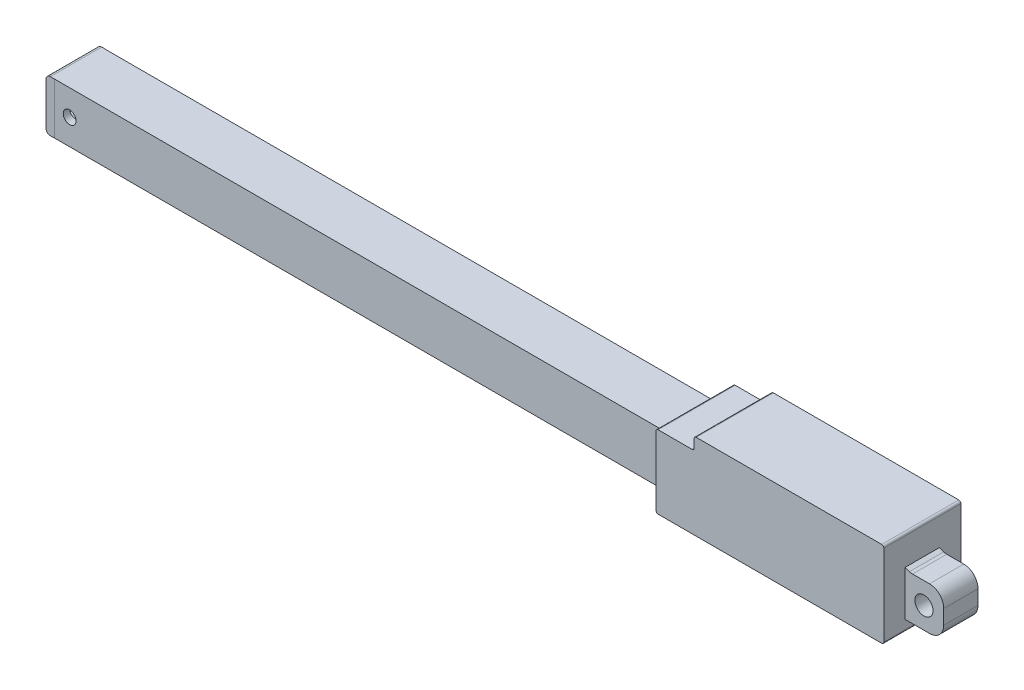
from build123d import *

# Parameters (mm, degrees)
SKETCH2_R           = 2.125
BOSS_EXTRUDE1_DEPTH = 9
SKETCH2_3_W         = 143.4775
SKETCH2_3_H         = 11.945
SKETCH2_3_R         = 1.5
BOSS_EXTRUDE2_DEPTH = 5.975
BOSS_EXTRUDE3_DEPTH = 6
SKETCH7_R           = 4.45
CUT_EXTRUDE4_DEPTH  = 138
CUT_EXTRUDE6_DEPTH  = 5
CUT_EXTRUDE7_DEPTH  = 5


with BuildPart() as part:
    # Sketch2 → Boss-Extrude1 (new, symmetric)
    with BuildSketch(Plane.XY):
        with BuildLine():
            Line((145.4775, 14.0125), (145.4775, 11.945))
            Line((145.4775, 11.945), (145.4775, 0))
            Line((145.4775, 0), (145.4775, -2.0675))
            ThreePointArc((145.4775, -2.0675), (145.623946609, -2.421053391), (145.9775, -2.5675))
            Line((145.9775, -2.5675), (198.1775, -2.5675))
            ThreePointArc((198.1775, -2.5675), (198.531053391, -2.421053391), (198.6775, -2.0675))
            Line((198.6775, -2.0675), (198.6775, 0))
            Line((198.6775, 0), (204.343857791, 0))
            ThreePointArc((204.343857791, 0), (206.701098803, 0.976401197), (207.6775, 3.333642209))
            Line((207.6775, 3.333642209), (207.6775, 6.708857791))
            ThreePointArc((207.6775, 6.708857791), (206.701098803, 9.066098803), (204.343857791, 10.0425))
            Line((204.343857791, 10.0425), (200.377364582, 10.0425))
            ThreePointArc((200.377364582, 10.0425), (200.021766481, 10.074366369), (199.6775, 10.168950009))
            Line((199.6775, 10.168950009), (198.6775, 10.5425))
            Line((198.6775, 10.5425), (198.6775, 16.9325))
            ThreePointArc((198.6775, 16.9325), (198.531053391, 17.286053391), (198.1775, 17.4325))
            Line((198.1775, 17.4325), (154.8775, 17.4325))
            ThreePointArc((154.8775, 17.4325), (154.523946609, 17.286053391), (154.3775, 16.9325))
            Line((154.3775, 16.9325), (154.3775, 15.0125))
            ThreePointArc((154.3775, 15.0125), (154.231053391, 14.658946609), (153.8775, 14.5125))
            Line((153.8775, 14.5125), (145.9775, 14.5125))
            ThreePointArc((145.9775, 14.5125), (145.623946609, 14.366053391), (145.4775, 14.0125))
        make_face()
        with Locations((203.0525, 5.02125)):
            Circle(SKETCH2_R, mode=Mode.SUBTRACT)
    extrude(amount=BOSS_EXTRUDE1_DEPTH, both=True)

    # Sketch2_3 → Boss-Extrude2 (add, symmetric)
    with BuildSketch(Plane.XY):
        with Locations((73.73875, 5.9725)):
            Rectangle(SKETCH2_3_W, SKETCH2_3_H)
        with Locations((5.5, 5.9725)):
            Circle(SKETCH2_3_R, mode=Mode.SUBTRACT)
    extrude(amount=BOSS_EXTRUDE2_DEPTH, both=True)

    # Sketch2_4 → Boss-Extrude3 (add, symmetric)
    with BuildSketch(Plane.XY):
        with BuildLine():
            Line((2, 0), (2, 11.945))
            Line((2, 11.945), (1, 11.945))
            ThreePointArc((1, 11.945), (0.292893219, 11.652106781), (0, 10.945))
            Line((0, 10.945), (0, 1))
            ThreePointArc((0, 1), (0.292893219, 0.292893219), (1, 0))
            Line((1, 0), (2, 0))
        make_face()
    extrude(amount=BOSS_EXTRUDE3_DEPTH, both=True)

    # Sketch7 → Cut-Extrude4 (cut)
    with BuildSketch(Plane.ZY):
        with Locations((0, 5.9725)):
            Circle(SKETCH7_R)
    extrude(amount=-CUT_EXTRUDE4_DEPTH, mode=Mode.SUBTRACT)

    # Sketch8 → Cut-Extrude6 (cut, symmetric)
    with BuildSketch(Plane.XY.offset(9)):
        Polygon((198.6775, 10.5425), (211.452070609, 15.905902501), (207.012502563, -2.059702975), (198.6775, 0), align=None)
    extrude(amount=CUT_EXTRUDE6_DEPTH, both=True, mode=Mode.SUBTRACT)

    # Sketch10 → Cut-Extrude7 (cut, symmetric)
    with BuildSketch(Plane(origin=(0, 0, -9), x_dir=(-1, 0, 0), z_dir=(0, 0, -1))):
        Polygon((-198.6775, 10.5425), (-218.686725566, 39.11278538), (-201.443333916, -35.592944689), (-198.6775, 0), align=None)
    extrude(amount=CUT_EXTRUDE7_DEPTH, both=True, mode=Mode.SUBTRACT)


solid = part.part
